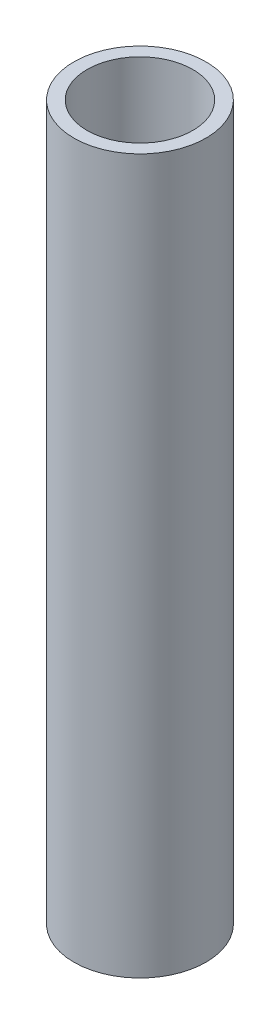
from build123d import *

# Parameters (mm, degrees)
CROQUIS1_R              = 5
CROQUIS1_R_2            = 4
SALIENTE_EXTRUIR1_DEPTH = 54


with BuildPart() as part:
    # Croquis1 → Saliente-Extruir1 (new body)
    with BuildSketch(Plane(origin=(0, 0, 0), x_dir=(1, 0, 0), z_dir=(0, 1, 0))):
        Circle(CROQUIS1_R)
        Circle(CROQUIS1_R_2, mode=Mode.SUBTRACT)
    extrude(amount=SALIENTE_EXTRUIR1_DEPTH)


solid = part.part
